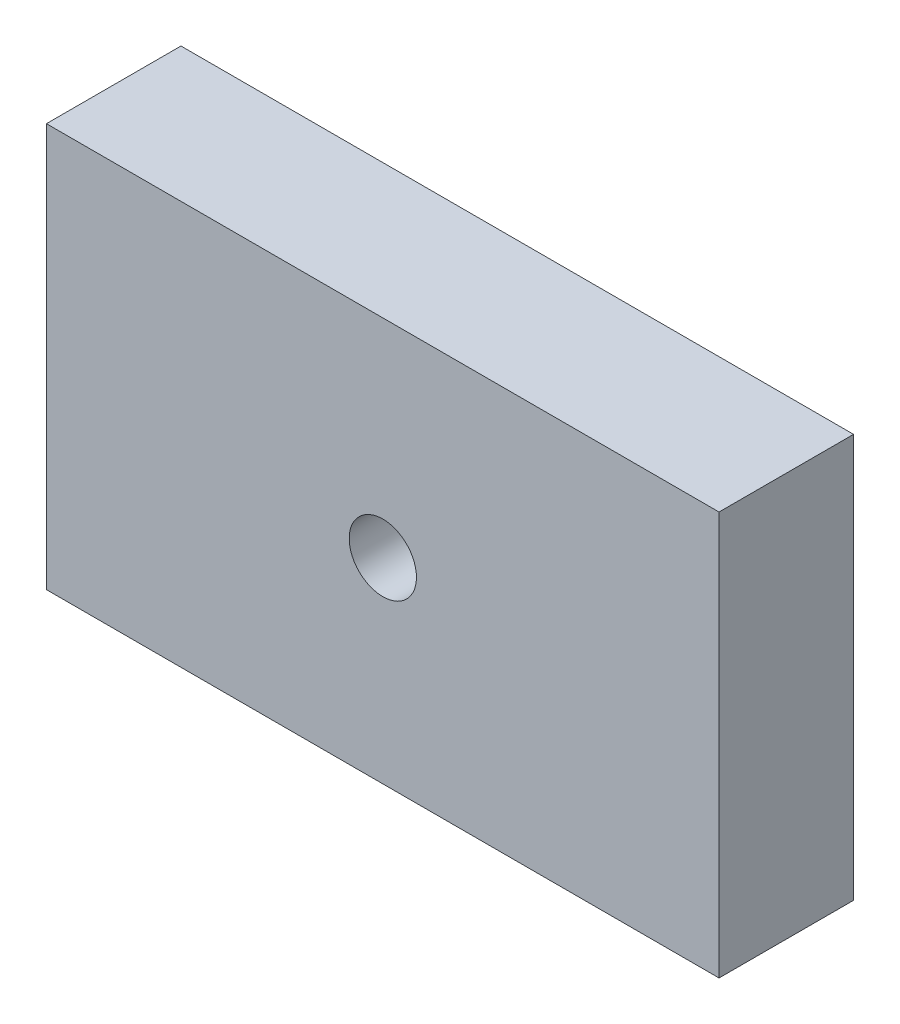
from build123d import *

# Parameters (mm, degrees)
SKETCH1_W           = 50
SKETCH1_H           = 30
BOSS_EXTRUDE1_DEPTH = 10
SKETCH2_R           = 2.5
CUT_EXTRUDE1_DEPTH  = 10


with BuildPart() as part:
    # Sketch1 → Boss-Extrude1 (new body)
    with BuildSketch(Plane.XY):
        with Locations((22.961410819, -15)):
            Rectangle(SKETCH1_W, SKETCH1_H)
    extrude(amount=BOSS_EXTRUDE1_DEPTH)

    # Sketch2 → Cut-Extrude1 (cut)
    with BuildSketch(Plane.XY.offset(10)):
        with Locations((22.96810558, -15.448051393)):
            Circle(SKETCH2_R)
    extrude(amount=-CUT_EXTRUDE1_DEPTH, mode=Mode.SUBTRACT)


solid = part.part
